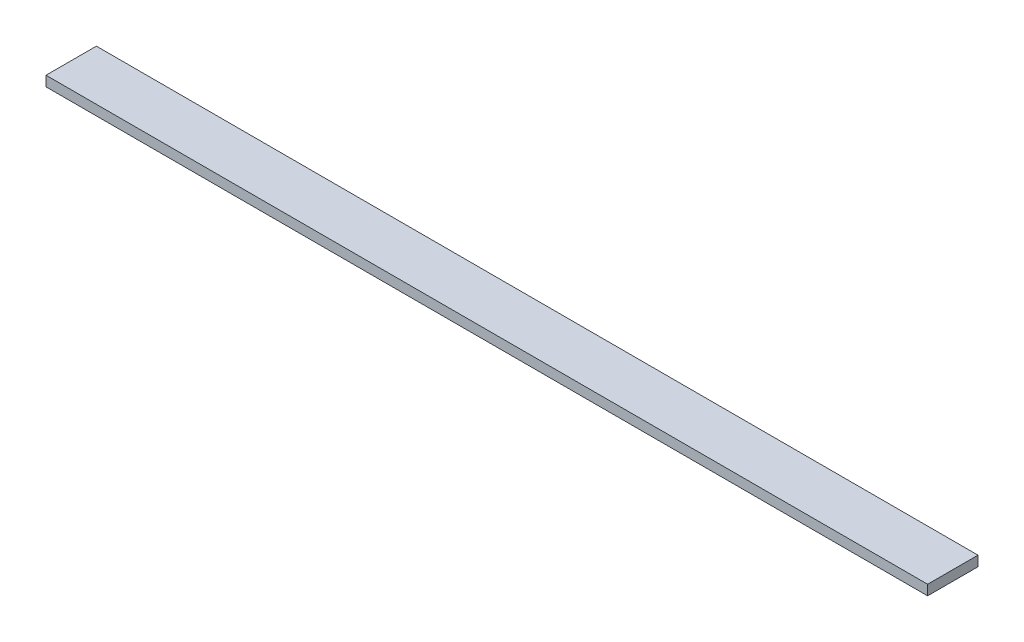
from build123d import *

# Parameters (mm, degrees)
SKETCH_1_W      = 20
SKETCH_1_H      = 4
EXTRUDE_1_DEPTH = 350


with BuildPart() as part:
    # Эскиз1 → Бобышка-Вытянуть1 (new body)
    with BuildSketch(Plane(origin=(0, 0, 0), x_dir=(0, 0, -1), z_dir=(1, 0, 0))):
        with Locations((10, 2)):
            Rectangle(SKETCH_1_W, SKETCH_1_H)
    extrude(amount=EXTRUDE_1_DEPTH)


solid = part.part
